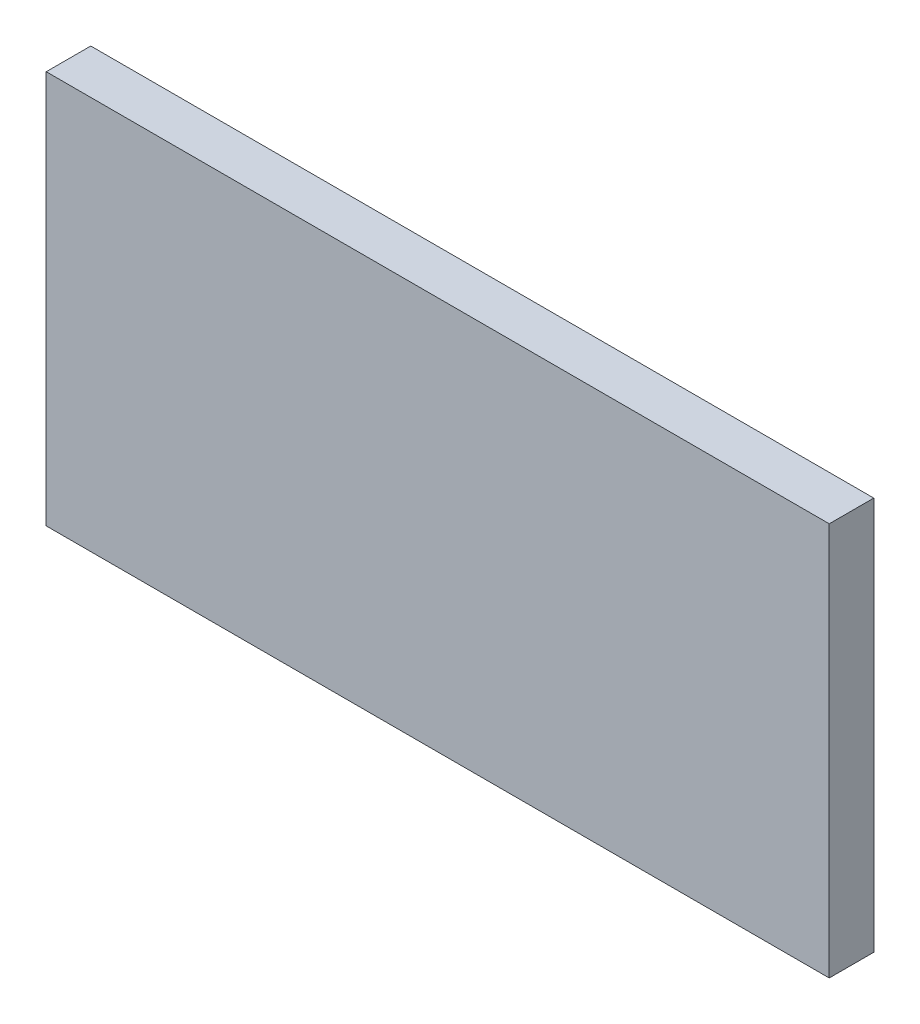
from build123d import *

# Parameters (mm, degrees)
SKETCH1_W           = 13.3985
SKETCH1_H           = 6.731
BOSS_EXTRUDE1_DEPTH = 0.762


with BuildPart() as part:
    # Sketch1 → Boss-Extrude1 (new body)
    with BuildSketch(Plane.XY):
        with Locations((-1.76873705, -109.940627468)):
            Rectangle(SKETCH1_W, SKETCH1_H)
    extrude(amount=BOSS_EXTRUDE1_DEPTH)


solid = part.part
